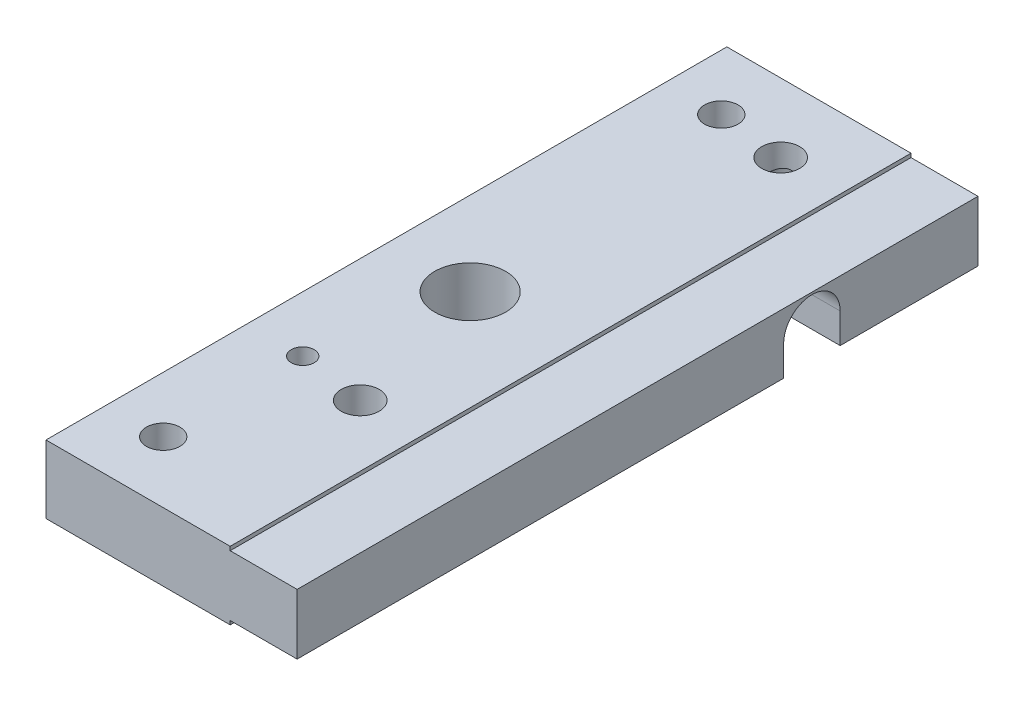
from build123d import *

# Parameters (mm, degrees)
SKETCH1_W                                        = 61
SKETCH1_H                                        = 6.1
BOSS_EXTRUDE1_DEPTH                              = 22.5
SKETCH2_OUTSIDE_W                                = 76.06
SKETCH2_OUTSIDE_H                                = 21.16
SKETCH2_OUTSIDE_W_2                              = 61
SKETCH2_OUTSIDE_H_2                              = 5.41284
CUT_EXTRUDE1_DEPTH                               = 6
CUT_EXTRUDE3_DEPTH                               = 23.5
SKETCH6_R                                        = 3.175
CUT_EXTRUDE4_DEPTH                               = 7.1
SKETCH7_R                                        = 1.5
CUT_EXTRUDE5_DEPTH                               = 7.1
M2_5X0_45_TAPPED_HOLE1_D                         = 2.05
M2_5X0_45_TAPPED_HOLE2_D                         = 2.05
M2_5X0_45_TAPPED_HOLE2_DEPTH                     = 7.3
M2_5X0_45_TAPPED_HOLE2_TIP                       = 0.615882135
CBORE_FOR_M3_PAN_HEAD_MACHINE_SCREW1_D           = 3.4
CBORE_FOR_M3_PAN_HEAD_MACHINE_SCREW1_CBORE_D     = 6.5
CBORE_FOR_M3_PAN_HEAD_MACHINE_SCREW1_CBORE_DEPTH = 2.2


with BuildPart() as part:
    # Sketch1 → Boss-Extrude1 (new body)
    with BuildSketch(Plane(origin=(0, 0, 0), x_dir=(0, 0, -1), z_dir=(1, 0, 0))):
        with Locations((30.5, 0)):
            Rectangle(SKETCH1_W, SKETCH1_H)
    extrude(amount=BOSS_EXTRUDE1_DEPTH)

    # Sketch2 outside → Cut-Extrude1 (cut)
    with BuildSketch(Plane(origin=(22.5, 0, 0), x_dir=(0, 0, -1), z_dir=(1, 0, 0))):
        with Locations((30.5, 0)):
            Rectangle(SKETCH2_OUTSIDE_W, SKETCH2_OUTSIDE_H)
        with Locations((30.5, 0)):
            Rectangle(SKETCH2_OUTSIDE_W_2, SKETCH2_OUTSIDE_H_2, mode=Mode.SUBTRACT)
    extrude(amount=-CUT_EXTRUDE1_DEPTH, mode=Mode.SUBTRACT)

    # Sketch5 → Cut-Extrude3 (cut, through all)
    with BuildSketch(Plane.ZY):
        with BuildLine():
            Line((-43.5866, -0.01898), (-43.5866, -3.05))
            Line((-43.5866, -3.05), (-48.6514, -3.05))
            Line((-48.6514, -3.05), (-48.6514, -0.01898))
            ThreePointArc((-48.6514, -0.01898), (-46.119, 2.51342), (-43.5866, -0.01898))
        make_face()
    extrude(amount=-CUT_EXTRUDE3_DEPTH, mode=Mode.SUBTRACT)

    # Sketch6 → Cut-Extrude4 (cut, through all)
    with BuildSketch(Plane(origin=(0, 3.05, 0), x_dir=(1, 0, 0), z_dir=(0, 1, 0))):
        with Locations(Location((7.5, 30.5, 0), (0, 0, 270))):  # turned: the seam where the file's is
            Circle(SKETCH6_R)
    extrude(amount=-CUT_EXTRUDE4_DEPTH, mode=Mode.SUBTRACT)

    # Sketch7 → Cut-Extrude5 (cut, through all)
    with BuildSketch(Plane(origin=(0, 3.05, 0), x_dir=(1, 0, 0), z_dir=(0, 1, 0))):
        with Locations(Location((5, 55.5, 0), (0, 0, 270))):  # turned: the seam where the file's is
            Circle(SKETCH7_R)
        with Locations(Location((5, 5.5, 0), (0, 0, 270))):  # turned: the seam where the file's is
            Circle(SKETCH7_R)
    extrude(amount=-CUT_EXTRUDE5_DEPTH, mode=Mode.SUBTRACT)

    # M2.5x0.45 Tapped Hole1 (through all)
    with Locations(Plane(origin=(0, -3.05, 0), x_dir=(-1, 0, 0), z_dir=(0, -1, 0))):
        with Locations((-5, 18)):
            Hole(M2_5X0_45_TAPPED_HOLE1_D / 2)

    # M2.5x0.45 Tapped Hole2
    with Locations(Plane(origin=(0, 0, -61), x_dir=(-1, 0, 0), z_dir=(0, 0, -1))):
        with Locations((-10, 0)):
            Hole(M2_5X0_45_TAPPED_HOLE2_D / 2, depth=M2_5X0_45_TAPPED_HOLE2_DEPTH)
            with Locations((0, 0, -(M2_5X0_45_TAPPED_HOLE2_DEPTH + M2_5X0_45_TAPPED_HOLE2_TIP / 2))):  # 118° drill point
                Cone(0, M2_5X0_45_TAPPED_HOLE2_D / 2, M2_5X0_45_TAPPED_HOLE2_TIP, mode=Mode.SUBTRACT)

    # CBORE for M3 Pan Head Machine Screw1 (through all)
    with Locations(Plane(origin=(0, -3.05, 0), x_dir=(-1, 0, 0), z_dir=(0, -1, 0))):
        with Locations((-11, 54.825), (-11, 17.15)):
            CounterBoreHole(CBORE_FOR_M3_PAN_HEAD_MACHINE_SCREW1_D / 2, CBORE_FOR_M3_PAN_HEAD_MACHINE_SCREW1_CBORE_D / 2, CBORE_FOR_M3_PAN_HEAD_MACHINE_SCREW1_CBORE_DEPTH)


solid = part.part
